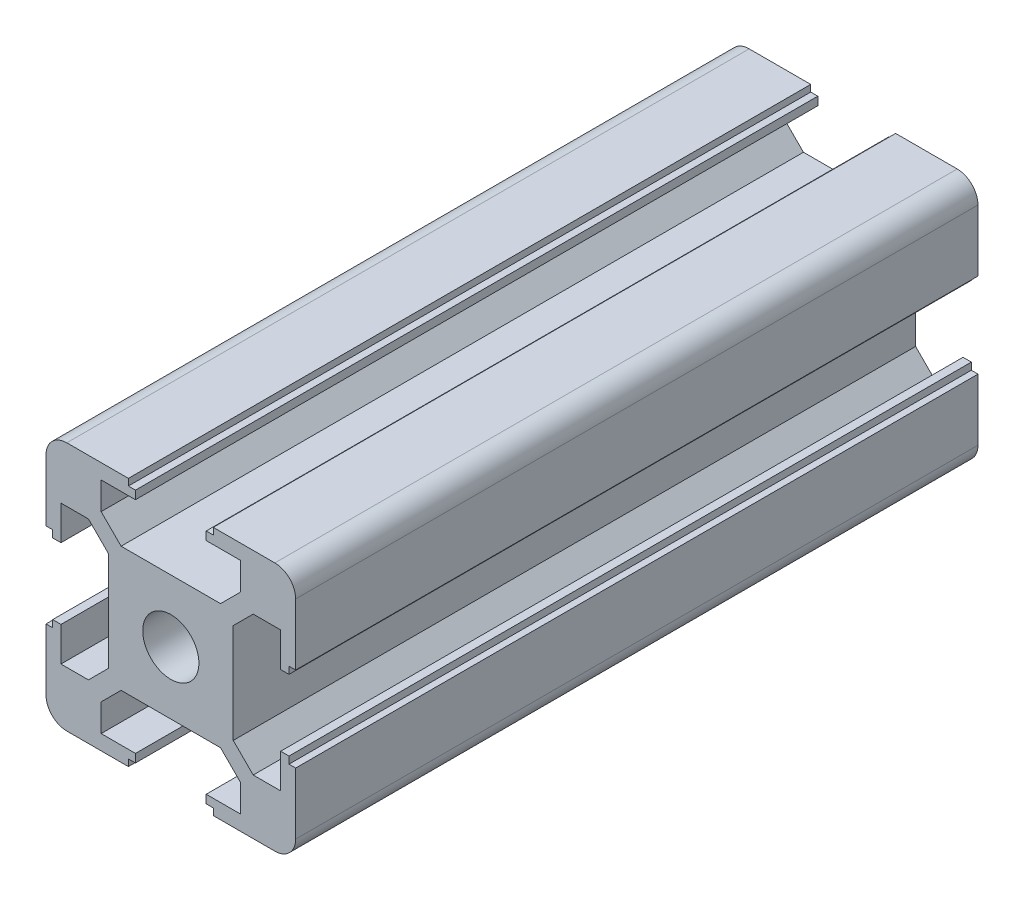
from build123d import *

# Parameters (mm, degrees)
SKETCH1_W                = 30
SKETCH1_H                = 30
BOSS_EXTRUDE1_DEPTH      = 41
SKETCH2_R                = 3.375
CUT_EXTRUDE1_DEPTH       = 83
FILLET1_R                = 2.5
CUT_EXTRUDE2_DEPTH       = 83
CIRPATTERN1_COUNT        = 4
CIRPATTERN1_COPY_1_DEPTH = 83
CIRPATTERN1_COPY_2_DEPTH = 83
CIRPATTERN1_COPY_3_DEPTH = 83


with BuildPart() as part:
    # Sketch1 → Boss-Extrude1 (new body, symmetric)
    with BuildSketch(Plane.XY):
        Rectangle(SKETCH1_W, SKETCH1_H)
    extrude(amount=BOSS_EXTRUDE1_DEPTH, both=True)

    # Sketch2 → Cut-Extrude1 (cut, through all)
    with BuildSketch(Plane.XY.offset(41)):
        Circle(SKETCH2_R)
    extrude(amount=-CUT_EXTRUDE1_DEPTH, mode=Mode.SUBTRACT)

    # Fillet1
    fillet1_edges = [part.edges().sort_by_distance(p)[0] for p in [
        (15, -15, 0),
        (-15, -15, 0),
        (-15, 15, 0),
        (15, 15, 0),
    ]]
    fillet(fillet1_edges, radius=FILLET1_R)

    # Sketch3 → Cut-Extrude2 (cut, through all)
    with BuildSketch(Plane.XY.offset(41)):
        Polygon((0, 15), (-5.1, 15), (-5.1, 14.2), (-4.25, 14.2), (-4.25, 13.2), (-8.375, 13.2), (-8.375, 9.9), (-5.975, 7.5), (0, 7.5), align=None)
    cut_extrude2 = extrude(amount=-CUT_EXTRUDE2_DEPTH, mode=Mode.SUBTRACT)

    # Mirror1: Cut-Extrude2 across plane
    add(cut_extrude2.mirror(Plane(origin=(0, 0, 0), x_dir=(0, 0, 1), z_dir=(1, 0, 0))), mode=Mode.SUBTRACT)

    # CirPattern1: Cut-Extrude2 ×4 about axis
    cirpattern1_axis = Axis((0, 0, 0), (0, 0, 1))
    for i in range(1, CIRPATTERN1_COUNT):
        add(cut_extrude2.rotate(cirpattern1_axis, i * 360 / CIRPATTERN1_COUNT), mode=Mode.SUBTRACT)

    # CirPattern1 copy 1 sketch → CirPattern1 copy 1 (cut, through all)
    with BuildSketch(Plane(origin=(0, 0, 41), x_dir=(0, -1, 0), z_dir=(0, 0, 1))):
        Polygon((0, -15), (-5.1, -15), (-5.1, -14.2), (-4.25, -14.2), (-4.25, -13.2), (-8.375, -13.2), (-8.375, -9.9), (-5.975, -7.5), (0, -7.5), align=None)
    extrude(amount=-CIRPATTERN1_COPY_1_DEPTH, mode=Mode.SUBTRACT)

    # CirPattern1 copy 2 sketch → CirPattern1 copy 2 (cut, through all)
    with BuildSketch(Plane.XY.offset(41)):
        Polygon((0, -15), (-5.1, -15), (-5.1, -14.2), (-4.25, -14.2), (-4.25, -13.2), (-8.375, -13.2), (-8.375, -9.9), (-5.975, -7.5), (0, -7.5), align=None)
    extrude(amount=-CIRPATTERN1_COPY_2_DEPTH, mode=Mode.SUBTRACT)

    # CirPattern1 copy 3 sketch → CirPattern1 copy 3 (cut, through all)
    with BuildSketch(Plane(origin=(0, 0, 41), x_dir=(0, 1, 0), z_dir=(0, 0, 1))):
        Polygon((0, -15), (-5.1, -15), (-5.1, -14.2), (-4.25, -14.2), (-4.25, -13.2), (-8.375, -13.2), (-8.375, -9.9), (-5.975, -7.5), (0, -7.5), align=None)
    extrude(amount=-CIRPATTERN1_COPY_3_DEPTH, mode=Mode.SUBTRACT)


solid = part.part
